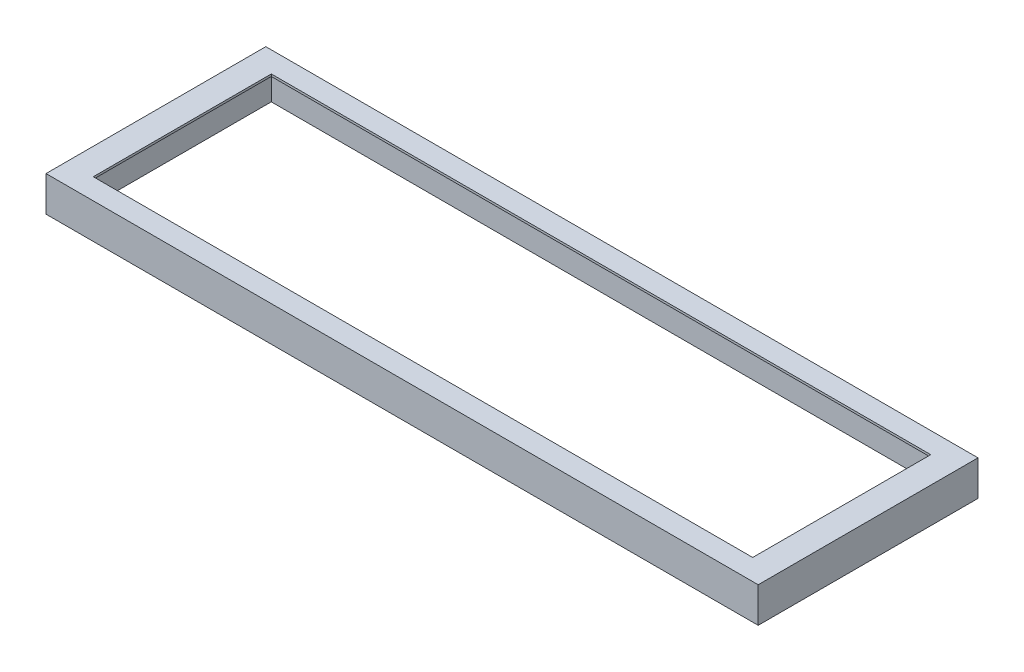
from build123d import *

# Parameters (mm, degrees)
CROQUIS1_W              = 1028.7
CROQUIS1_H              = 317.5
SALIENTE_EXTRUIR1_DEPTH = 50.8
CROQUIS6_W              = 984.25
CROQUIS6_H              = 288.925
CORTAR_EXTRUIR6_DEPTH   = 47.625
CROQUIS1_4_W            = 895.35
CROQUIS1_4_H            = 200.025
CORTAR_EXTRUIR1_DEPTH   = 541.683017118
CROQUIS7_W              = 952.5
CROQUIS7_H              = 257.175
CORTAR_EXTRUIR7_DEPTH   = 541.683017118


with BuildPart() as part:
    # Croquis1 → Saliente-Extruir1 (new body)
    with BuildSketch(Plane(origin=(0, 0, 0), x_dir=(1, 0, 0), z_dir=(0, 1, 0))):
        Rectangle(CROQUIS1_W, CROQUIS1_H)
    extrude(amount=SALIENTE_EXTRUIR1_DEPTH)

    # Croquis6 → Cortar-Extruir6 (cut)
    with BuildSketch(Plane(origin=(0, 0, 0), x_dir=(-1, 0, 0), z_dir=(0, -1, 0))):
        Rectangle(CROQUIS6_W, CROQUIS6_H)
    extrude(amount=-CORTAR_EXTRUIR6_DEPTH, mode=Mode.SUBTRACT)

    # Croquis1_4 → Cortar-Extruir1 (cut, through all)
    with BuildSketch(Plane(origin=(0, 0, 0), x_dir=(1, 0, 0), z_dir=(0, 1, 0))):
        Rectangle(CROQUIS1_4_W, CROQUIS1_4_H)
    extrude(amount=CORTAR_EXTRUIR1_DEPTH, mode=Mode.SUBTRACT)

    # Croquis7 → Cortar-Extruir7 (cut, through all)
    with BuildSketch(Plane(origin=(0, 50.8, 0), x_dir=(1, 0, 0), z_dir=(0, 1, 0))):
        Rectangle(CROQUIS7_W, CROQUIS7_H)
    extrude(amount=-CORTAR_EXTRUIR7_DEPTH, mode=Mode.SUBTRACT)


solid = part.part
